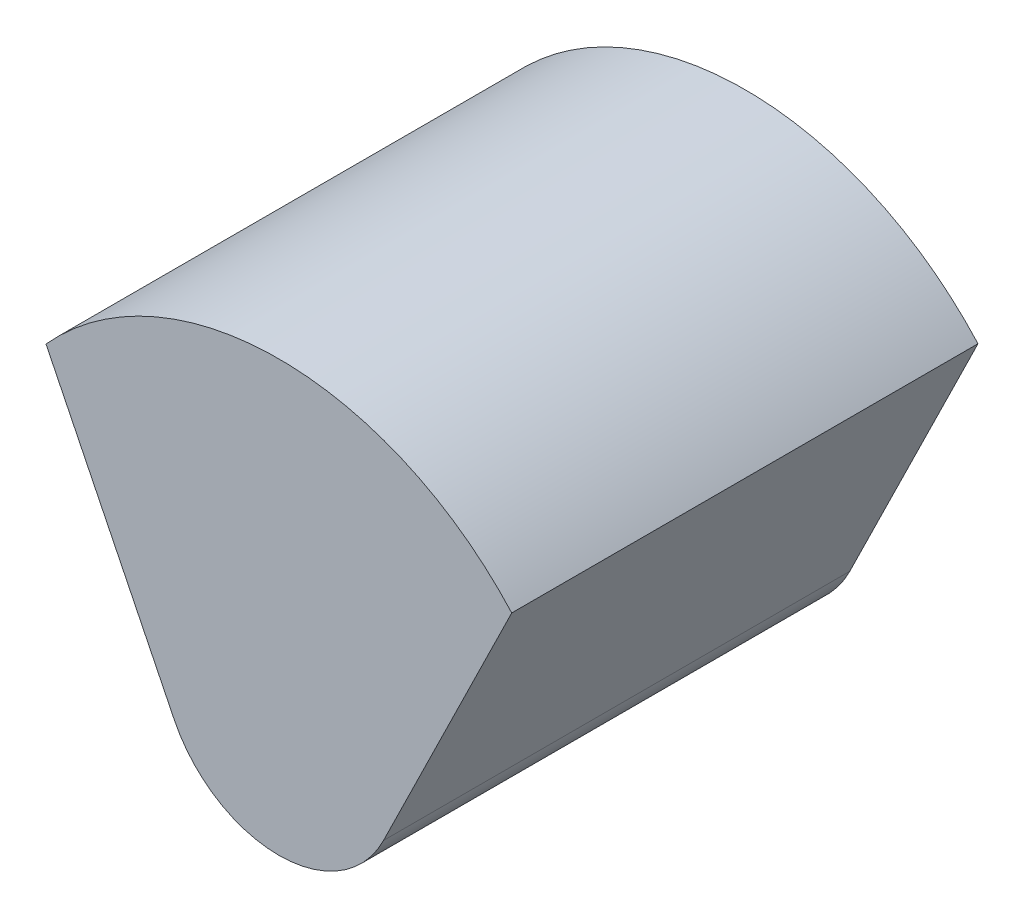
from build123d import *

# Parameters (mm, degrees)
BOSS_EXTRU_1_DEPTH = 4


with BuildPart() as part:
    # Esquisse1 → Boss.-Extru.1 (new body)
    with BuildSketch(Plane.XY.offset(6)):
        with BuildLine():
            Line((0.822356685, 14.759277321), (-0.277787755, 17))
            ThreePointArc((-0.277787755, 17), (1.72, 17.889080868), (3.717787755, 17))
            Line((3.717787755, 17), (2.617643315, 14.759277321))
            ThreePointArc((2.617643315, 14.759277321), (1.72, 14.2), (0.822356685, 14.759277321))
        make_face()
    extrude(amount=-BOSS_EXTRU_1_DEPTH)


solid = part.part
